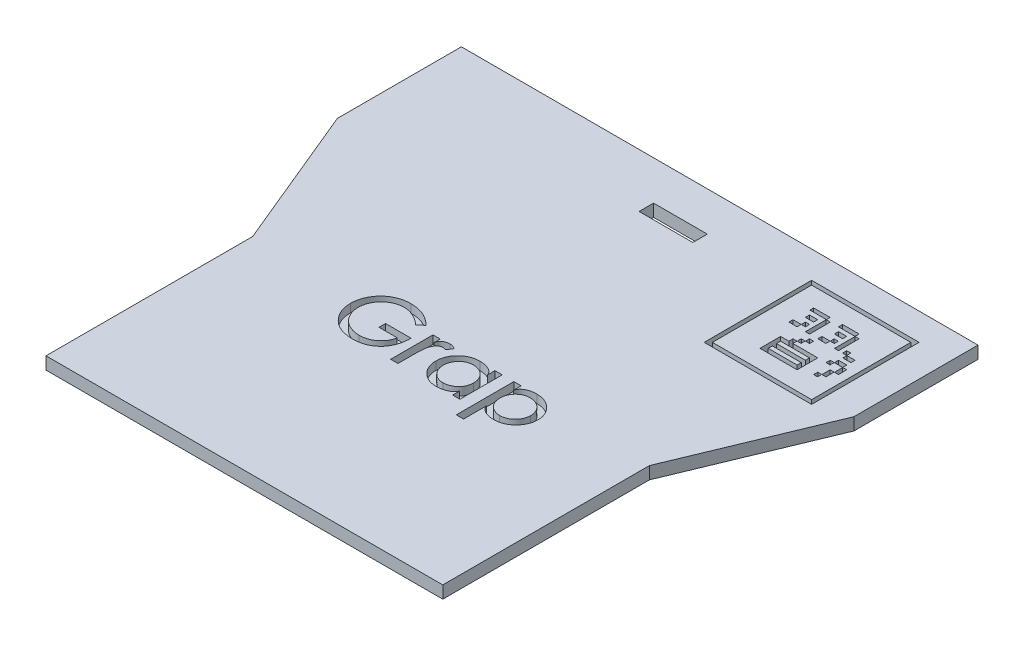
from build123d import *

# Parameters (mm, degrees)
CROQUIS1_W              = 40
CROQUIS1_H              = 20
CROQUIS1_W_2            = 20
CROQUIS1_H_2            = 40
SALIENTE_EXTRUIR1_DEPTH = 40
SALIENTE_EXTRUIR2_DEPTH = 5
CROQUIS3_W              = 13
CROQUIS3_H              = 3.5
CORTAR_EXTRUIR1_DEPTH   = 62
CROQUIS4_W              = 147.742850119
CROQUIS4_H              = 51.92034425
CORTAR_EXTRUIR2_DEPTH   = 152
CORTAR_EXTRUIR3_DEPTH   = 2
CROQUIS6_W              = 26
CROQUIS6_H              = 26
CROQUIS6_W_2            = 24
CROQUIS6_H_2            = 24
CORTAR_EXTRUIR7_DEPTH   = 2
CROQUIS7_W              = 3.990953792
CROQUIS7_H              = 0.897964604
CROQUIS7_W_2            = 1.970533435
CROQUIS7_H_2            = 0.997738449
CORTAR_EXTRUIR8_DEPTH   = 2
CROQUIS8_W              = 0.992886959
CROQUIS8_H              = 5.031193214
CORTAR_EXTRUIR10_DEPTH  = 2
CROQUIS9_W              = 1.005466888
CROQUIS9_H              = 1.003796718
CROQUIS9_W_2            = 1.973221998
CROQUIS9_H_2            = 1
CROQUIS9_W_3            = 4
CROQUIS9_W_4            = 0.964797176
CROQUIS9_H_3            = 5
CROQUIS9_W_5            = 2
CROQUIS9_W_6            = 1
CROQUIS9_H_4            = 0.952415725
CROQUIS9_W_7            = 1.95780875
CROQUIS9_W_8            = 1.970226015
CROQUIS9_W_9            = 0.956721573
CROQUIS9_W_10           = 0.966245303
CROQUIS9_H_5            = 2
CROQUIS9_W_11           = 0.963731959
CROQUIS9_W_12           = 0.946325397
CROQUIS9_W_13           = 0.94926307
CROQUIS9_W_14           = 0.978896183
CROQUIS9_H_6            = 1.388930129
CORTAR_EXTRUIR11_DEPTH  = 2
CROQUIS10_W             = 9
CROQUIS10_H             = 5
CROQUIS10_W_2           = 7
CROQUIS10_H_2           = 1
CORTAR_EXTRUIR12_DEPTH  = 2


with BuildPart() as part:
    # Croquis1 → Saliente-Extruir1 (new body)
    with BuildSketch(Plane(origin=(0, 0, 0), x_dir=(1, 0, 0), z_dir=(0, 1, 0))):
        Polygon((9.791730439, 53.63143583), (-115.208269561, 53.63143583), (-115.208269561, 23.63143583), (-100.708269561, -11.36856417), (-100.708269561, -61.36856417), (-4.708269561, -61.36856417), (-4.708269561, -11.36856417), (9.791730439, 23.63143583), align=None)
        with Locations((-90.208269561, 38.63143583)):
            Rectangle(CROQUIS1_W, CROQUIS1_H, mode=Mode.SUBTRACT)
        with Locations((-85.708269561, -36.36856417)):
            Rectangle(CROQUIS1_W_2, CROQUIS1_H_2, mode=Mode.SUBTRACT)
        with Locations((-15.208269561, 38.63143583)):
            Rectangle(CROQUIS1_W, CROQUIS1_H, mode=Mode.SUBTRACT)
        with Locations((-19.708269561, -36.36856417)):
            Rectangle(CROQUIS1_W_2, CROQUIS1_H_2, mode=Mode.SUBTRACT)
    extrude(amount=SALIENTE_EXTRUIR1_DEPTH)

    # Croquis2 → Saliente-Extruir2 (add)
    with BuildSketch(Plane.XZ):
        Polygon((9.791730439, -53.63143583), (9.791730439, -23.63143583), (-4.708269561, 11.36856417), (-4.708269561, 61.36856417), (-100.708269561, 61.36856417), (-100.708269561, 11.36856417), (-115.208269561, -23.63143583), (-115.208269561, -53.63143583), align=None)
    extrude(amount=SALIENTE_EXTRUIR2_DEPTH)

    # Croquis3 → Cortar-Extruir1 (cut)
    with BuildSketch(Plane(origin=(0, 40, 0), x_dir=(1, 0, 0), z_dir=(0, 1, 0))):
        with Locations((-52.708269561, 42.38143583)):
            Rectangle(CROQUIS3_W, CROQUIS3_H)
    extrude(amount=-CORTAR_EXTRUIR1_DEPTH, mode=Mode.SUBTRACT)

    # Croquis4 → Cortar-Extruir2 (cut)
    with BuildSketch(Plane(origin=(9.791730439, 0, 0), x_dir=(0, 0, -1), z_dir=(1, 0, 0))):
        with Locations((-9.648235569, 23.960172125)):
            Rectangle(CROQUIS4_W, CROQUIS4_H)
    extrude(amount=-CORTAR_EXTRUIR2_DEPTH, mode=Mode.SUBTRACT)

    # Croquis5 → Cortar-Extruir3 (cut)
    with BuildSketch(Plane(origin=(0, -2, 0), x_dir=(1, 0, 0), z_dir=(0, 1, 0))):
        with BuildLine():
            Line((-61.107219812, -9.007277638), (-62.44391686, -10.170341874))
            add(Edge.make_bspline(
                [(-62.44391686, -10.170341874), (-62.65362633, -9.987223191), (-63.061875839, -9.630738991), (-63.701108315, -9.159841224), (-64.343917636, -8.76265185), (-64.990474004, -8.44391251), (-65.62986377, -8.18862318), (-66.265000491, -8.013112652), (-66.890834022, -7.89844897), (-67.306999029, -7.884278333), (-67.51234134, -7.877286319)],
                knots=[0, 0, 0, 0, 0.000834946, 0.001625421, 0.002378884, 0.0030987, 0.003785538, 0.004440865, 0.005072944, 0.005688593, 0.005688593, 0.005688593, 0.005688593], degree=3))
            add(Edge.make_bspline(
                [(-67.51234134, -7.877286319), (-67.630951678, -7.879144317), (-67.867801497, -7.882854503), (-68.22117472, -7.921006086), (-68.571102497, -7.977916251), (-68.917797859, -8.059364387), (-69.261994259, -8.159789097), (-69.601057018, -8.287853385), (-69.937072461, -8.437654718), (-70.267317248, -8.610047847), (-70.588301816, -8.801288153), (-70.893374791, -9.011758013), (-71.180634208, -9.241115678), (-71.45061838, -9.488712221), (-71.701741729, -9.75492556), (-71.937725766, -10.035925909), (-72.152458558, -10.338300474), (-72.350120096, -10.655537634), (-72.524430099, -10.985384364), (-72.681321574, -11.319903304), (-72.810479557, -11.661931393), (-72.915006494, -12.01032992), (-72.998259409, -12.364643224), (-73.058694647, -12.724480991), (-73.096093346, -13.090985292), (-73.099796126, -13.336985007), (-73.101664256, -13.461097083)],
                knots=[0, 0, 0, 0, 0.000355705, 0.000710297, 0.001065072, 0.001418731, 0.001778016, 0.002139945, 0.002505133, 0.002881113, 0.00325688, 0.003625371, 0.003992095, 0.004358808, 0.004723372, 0.005089307, 0.005458714, 0.005834997, 0.006209823, 0.006577292, 0.006942771, 0.007305486, 0.007667823, 0.008033925, 0.008399488, 0.008771721, 0.008771721, 0.008771721, 0.008771721], degree=3))
            add(Edge.make_bspline(
                [(-73.101664256, -13.461097083), (-73.098504682, -13.587941548), (-73.092196404, -13.84119403), (-73.057173854, -14.218173757), (-72.993055754, -14.588222734), (-72.90399165, -14.951758064), (-72.791467129, -15.30922645), (-72.65346294, -15.661548507), (-72.486277482, -16.005193628), (-72.300871918, -16.343319206), (-72.092232737, -16.66783323), (-71.861846798, -16.973714613), (-71.617492157, -17.264914398), (-71.351833962, -17.533325948), (-71.072879774, -17.787930132), (-70.770904322, -18.017533791), (-70.454392656, -18.233422593), (-70.12123654, -18.428995674), (-69.774384603, -18.601474989), (-69.419586759, -18.753657627), (-69.05568389, -18.880888407), (-68.684923399, -18.985758492), (-68.305360383, -19.065503326), (-67.919749011, -19.122728841), (-67.525966888, -19.160829715), (-67.260709556, -19.16437919), (-67.126490645, -19.166175208)],
                knots=[0, 0, 0, 0, 0.000380588, 0.000759867, 0.001134582, 0.001506243, 0.00188193, 0.002258102, 0.002640243, 0.003027597, 0.003414431, 0.003796423, 0.004175782, 0.004553877, 0.004928562, 0.00530783, 0.005690806, 0.006077463, 0.006465718, 0.006852217, 0.007234876, 0.007621405, 0.008007354, 0.008397521, 0.008790521, 0.009193059, 0.009193059, 0.009193059, 0.009193059], degree=3))
            add(Edge.make_bspline(
                [(-67.126490645, -19.166175208), (-66.959121917, -19.162408694), (-66.628980803, -19.154979103), (-66.14438368, -19.098088106), (-65.678387423, -19.010247082), (-65.235740125, -18.873721965), (-64.809383598, -18.711337051), (-64.405678135, -18.504475756), (-64.019789839, -18.264628028), (-63.660010763, -17.986348269), (-63.32471731, -17.686623121), (-63.026126115, -17.36395103), (-62.759096656, -17.028800997), (-62.533961044, -16.673124203), (-62.338538456, -16.306889503), (-62.183737808, -15.922375459), (-62.063743442, -15.52284957), (-62.014118004, -15.247625132), (-61.989164256, -15.109230763)],
                knots=[0, 0, 0, 0, 0.000501977, 0.000990168, 0.001462037, 0.001922426, 0.002377938, 0.002829059, 0.003281005, 0.003739087, 0.004191822, 0.00462864, 0.005056499, 0.005475458, 0.005889687, 0.006300148, 0.006716981, 0.00713858, 0.00713858, 0.00713858, 0.00713858], degree=3))
            Line((-61.989164256, -15.109230763), (-66.398886479, -15.109230763))
            Line((-66.398886479, -15.109230763), (-66.398886479, -13.521730763))
            Line((-66.398886479, -13.521730763), (-60.225275367, -13.521730763))
            add(Edge.make_bspline(
                [(-60.225275367, -13.521730763), (-60.231527527, -13.793980078), (-60.243732443, -14.325441305), (-60.341714945, -15.100134558), (-60.486185382, -15.832718068), (-60.697254271, -16.520101513), (-60.964692169, -17.163253655), (-61.291326014, -17.762189768), (-61.676514098, -18.316735334), (-62.117658138, -18.82376331), (-62.60810364, -19.278560773), (-63.14264914, -19.676844687), (-63.723691118, -20.007408471), (-64.343808432, -20.282027775), (-65.006434363, -20.49421392), (-65.70986279, -20.644503632), (-66.455192559, -20.737476847), (-66.966359313, -20.748184662), (-67.228465472, -20.753675208)],
                knots=[0, 0, 0, 0, 0.000816469, 0.001593839, 0.002339208, 0.00305409, 0.003747138, 0.004425491, 0.005096758, 0.005768789, 0.006437721, 0.007099742, 0.007763956, 0.008438925, 0.009130969, 0.009847236, 0.010594179, 0.011380245, 0.011380245, 0.011380245, 0.011380245], degree=3))
            add(Edge.make_bspline(
                [(-67.228465472, -20.753675208), (-67.382858489, -20.751418732), (-67.688264344, -20.746955183), (-68.139766754, -20.715679742), (-68.579701615, -20.667349812), (-69.006250268, -20.594798045), (-69.421716477, -20.505037817), (-69.822717001, -20.390242146), (-70.214708335, -20.263038712), (-70.590754996, -20.105790221), (-70.95886701, -19.937053039), (-71.312939697, -19.7428591), (-71.653297914, -19.526558164), (-71.987145951, -19.296710566), (-72.301653498, -19.038793849), (-72.607369167, -18.765132721), (-72.899582508, -18.470176327), (-73.083437607, -18.260398035), (-73.176078319, -18.154695173)],
                knots=[0, 0, 0, 0, 0.000463152, 0.000916164, 0.001357179, 0.00179034, 0.002213637, 0.00263159, 0.003041217, 0.003449126, 0.003853556, 0.004255641, 0.004659385, 0.005063092, 0.005470711, 0.005878583, 0.00629369, 0.006715289, 0.006715289, 0.006715289, 0.006715289], degree=3))
            add(Edge.make_bspline(
                [(-73.176078319, -18.154695173), (-73.311849304, -17.987275031), (-73.580474619, -17.656031295), (-73.918956317, -17.119479296), (-74.216117932, -16.57026445), (-74.452356585, -15.996849783), (-74.637955631, -15.404828981), (-74.771064498, -14.792576435), (-74.848500143, -14.160380427), (-74.859832269, -13.732319551), (-74.865553145, -13.51621861)],
                knots=[0, 0, 0, 0, 0.000646128, 0.001278376, 0.00189979, 0.002517575, 0.003135607, 0.003758901, 0.004394742, 0.005043007, 0.005043007, 0.005043007, 0.005043007], degree=3))
            add(Edge.make_bspline(
                [(-74.865553145, -13.51621861), (-74.863492359, -13.354394254), (-74.859408626, -13.033716884), (-74.808754024, -12.557203514), (-74.736116743, -12.088345139), (-74.631169309, -11.627882325), (-74.495595779, -11.176753904), (-74.328942188, -10.734312058), (-74.134396836, -10.299011554), (-73.907076675, -9.876160561), (-73.659671625, -9.465850833), (-73.381624659, -9.080829051), (-73.087186955, -8.713847421), (-72.766050677, -8.373716003), (-72.427430399, -8.050970834), (-72.061510537, -7.756960842), (-71.675875094, -7.482950954), (-71.267211216, -7.235515897), (-70.842186206, -7.013162637), (-70.401701352, -6.818149926), (-69.946617037, -6.657667337), (-69.480103528, -6.519913615), (-68.998544662, -6.419729192), (-68.504453483, -6.345751385), (-67.996586453, -6.296002586), (-67.653019625, -6.291874171), (-67.479268423, -6.289786319)],
                knots=[0, 0, 0, 0, 0.000485265, 0.00096162, 0.001436026, 0.001908056, 0.002377156, 0.002848114, 0.00332552, 0.003806375, 0.004287561, 0.004761734, 0.005230048, 0.00569803, 0.006164002, 0.006632316, 0.007104893, 0.007582291, 0.008064297, 0.008543102, 0.009026052, 0.009511012, 0.010001292, 0.01050021, 0.011009488, 0.011530569, 0.011530569, 0.011530569, 0.011530569], degree=3))
            add(Edge.make_bspline(
                [(-67.479268423, -6.289786319), (-67.333161803, -6.292378423), (-67.042539755, -6.297534402), (-66.610098797, -6.324366182), (-66.184052819, -6.373747457), (-65.765341055, -6.447375953), (-65.351462363, -6.53324746), (-64.946234745, -6.64471331), (-64.54808097, -6.774623888), (-64.155045689, -6.923854221), (-63.76550445, -7.094966512), (-63.378364356, -7.290661939), (-62.995278363, -7.515819131), (-62.612206645, -7.763348679), (-62.231547946, -8.036706613), (-61.85390814, -8.336059014), (-61.47470908, -8.657252981), (-61.231028523, -8.889352829), (-61.107219812, -9.007277638)],
                knots=[0, 0, 0, 0, 0.000438355, 0.000871936, 0.001299261, 0.001724269, 0.002146983, 0.002566858, 0.002984337, 0.003403043, 0.003827559, 0.004260193, 0.004703588, 0.005159974, 0.005628061, 0.00610886, 0.006605398, 0.007118243, 0.007118243, 0.007118243, 0.007118243], degree=3))
        make_face()
        with BuildLine():
            Line((-58.28499759, -10.170341874), (-56.521108701, -10.170341874))
            Line((-56.521108701, -10.170341874), (-56.521108701, -11.622794131))
            add(Edge.make_bspline(
                [(-56.521108701, -11.622794131), (-56.510465377, -11.556388161), (-56.48969112, -11.426773126), (-56.437289176, -11.240510201), (-56.364810536, -11.067579679), (-56.273709525, -10.907784797), (-56.165669761, -10.760518615), (-56.039594821, -10.626701113), (-55.896071177, -10.504457911), (-55.678932125, -10.36473568), (-55.393842755, -10.216953615), (-55.036132033, -10.088701138), (-54.669931273, -10.007452807), (-54.421391637, -9.99845695), (-54.296955055, -9.993952985)],
                knots=[0, 0, 0, 0, 0.000201646, 0.000393585, 0.000578878, 0.000762793, 0.000944151, 0.001125487, 0.001313224, 0.001508147, 0.001898898, 0.002273765, 0.002645662, 0.003018558, 0.003018558, 0.003018558, 0.003018558], degree=3))
            add(Edge.make_bspline(
                [(-54.296955055, -9.993952985), (-54.184407983, -10.000636438), (-53.94796047, -10.014677546), (-53.584766275, -10.108294511), (-53.202324773, -10.262804002), (-52.94971593, -10.400916748), (-52.816942034, -10.473510277)],
                knots=[0, 0, 0, 0, 0.000337605, 0.000709267, 0.0011187, 0.00157234, 0.00157234, 0.00157234, 0.00157234], degree=3))
            Line((-52.816942034, -10.473510277), (-53.65203318, -11.755085798))
            add(Edge.make_bspline(
                [(-53.65203318, -11.755085798), (-53.747289377, -11.728139669), (-53.921304692, -11.678914116), (-54.161168606, -11.62876584), (-54.350949411, -11.590758995), (-54.462209024, -11.584215196), (-54.509172937, -11.581452985)],
                knots=[0, 0, 0, 0, 0.000296839, 0.000542269, 0.000735292, 0.000876284, 0.000876284, 0.000876284, 0.000876284], degree=3))
            add(Edge.make_bspline(
                [(-54.509172937, -11.581452985), (-54.586126859, -11.587096161), (-54.748096212, -11.598973678), (-54.989709004, -11.692327134), (-55.237778851, -11.836356844), (-55.44215635, -11.997628632), (-55.606116572, -12.15526273), (-55.723421432, -12.299858494), (-55.837270442, -12.463504589), (-55.944148836, -12.647858192), (-56.042783551, -12.853074289), (-56.136064933, -13.076785957), (-56.225669798, -13.319838392), (-56.275073858, -13.491062053), (-56.30062259, -13.579608367)],
                knots=[0, 0, 0, 0, 0.000230409, 0.000484954, 0.000767664, 0.001089642, 0.001263099, 0.001449068, 0.001647084, 0.001860747, 0.00208755, 0.002329662, 0.002587734, 0.002864126, 0.002864126, 0.002864126, 0.002864126], degree=3))
            add(Edge.make_bspline(
                [(-56.30062259, -13.579608367), (-56.319277658, -13.652858961), (-56.361133097, -13.817207636), (-56.400538299, -14.096205848), (-56.440212727, -14.429587293), (-56.468121616, -14.818685475), (-56.49384423, -15.262389382), (-56.508475488, -15.762350245), (-56.520608385, -16.318169452), (-56.520936776, -16.707746252), (-56.521108701, -16.911704722)],
                knots=[0, 0, 0, 0, 0.000226619, 0.000508454, 0.000844164, 0.001233952, 0.001678373, 0.002177497, 0.002734333, 0.003346188, 0.003346188, 0.003346188, 0.003346188], degree=3))
            Line((-56.521108701, -16.911704722), (-56.521108701, -20.40089743))
            Line((-56.521108701, -20.40089743), (-58.28499759, -20.40089743))
            Line((-58.28499759, -20.40089743), (-58.28499759, -10.170341874))
        make_face()
        with BuildLine():
            Line((-41.528053145, -10.170341874), (-41.528053145, -20.40089743))
            Line((-41.528053145, -20.40089743), (-43.291942034, -20.40089743))
            Line((-43.291942034, -20.40089743), (-43.291942034, -18.694886145))
            add(Edge.make_bspline(
                [(-43.291942034, -18.694886145), (-43.323297454, -18.76831767), (-43.386242471, -18.91572914), (-43.512123658, -19.121863732), (-43.659423894, -19.317070999), (-43.830777414, -19.498650983), (-44.02486067, -19.667199335), (-44.241329622, -19.822804651), (-44.482544059, -19.962164614), (-44.832258426, -20.134727292), (-45.299899647, -20.313733116), (-45.891223776, -20.463284101), (-46.508681524, -20.561645992), (-46.930497517, -20.572015006), (-47.144936826, -20.577286319)],
                knots=[0, 0, 0, 0, 0.000239271, 0.000480329, 0.000722315, 0.000971889, 0.001227789, 0.001492429, 0.00177037, 0.002062488, 0.002661851, 0.00326815, 0.003889857, 0.004532738, 0.004532738, 0.004532738, 0.004532738], degree=3))
            add(Edge.make_bspline(
                [(-47.144936826, -20.577286319), (-47.325231177, -20.572406265), (-47.680833422, -20.562781126), (-48.204498615, -20.489825414), (-48.707464217, -20.368415463), (-49.190935284, -20.199704618), (-49.653556363, -19.980435864), (-50.095530256, -19.712049787), (-50.516122511, -19.39499362), (-50.913028362, -19.037304594), (-51.27409929, -18.642740615), (-51.593714786, -18.22327916), (-51.861236703, -17.779707544), (-52.084376573, -17.317326872), (-52.255813074, -16.832036711), (-52.376541205, -16.325816628), (-52.449830498, -15.798557066), (-52.459334074, -15.440195676), (-52.464164256, -15.258058888)],
                knots=[0, 0, 0, 0, 0.00054076, 0.001066564, 0.001582621, 0.002090794, 0.00259996, 0.003115641, 0.003639295, 0.004177867, 0.004716255, 0.005241568, 0.005757249, 0.006267599, 0.006779288, 0.007298023, 0.007826558, 0.008372825, 0.008372825, 0.008372825, 0.008372825], degree=3))
            add(Edge.make_bspline(
                [(-52.464164256, -15.258058888), (-52.459579832, -15.080467732), (-52.450512314, -14.729210782), (-52.372983353, -14.213459372), (-52.25373258, -13.71550345), (-52.077240074, -13.240055053), (-51.856433167, -12.782195032), (-51.58420468, -12.344788973), (-51.262297132, -11.927272129), (-50.896362988, -11.533757119), (-50.494262812, -11.176965507), (-50.07074994, -10.859039848), (-49.62591905, -10.590788019), (-49.160572316, -10.371513687), (-48.67435413, -10.202795218), (-48.169516957, -10.08172788), (-47.644103373, -10.008276128), (-47.287570497, -9.99877979), (-47.106351756, -9.993952985)],
                knots=[0, 0, 0, 0, 0.000532501, 0.001053231, 0.001561255, 0.002066099, 0.002571484, 0.003083906, 0.003608698, 0.004150826, 0.004693501, 0.005219363, 0.005737402, 0.006249061, 0.006759836, 0.007278571, 0.007804376, 0.008347889, 0.008347889, 0.008347889, 0.008347889], degree=3))
            add(Edge.make_bspline(
                [(-47.106351756, -9.993952985), (-46.887286608, -9.999921151), (-46.457846241, -10.011620736), (-45.83054715, -10.115013972), (-45.232949811, -10.275775304), (-44.764228115, -10.46873416), (-44.415173654, -10.652706379), (-44.178848932, -10.803425059), (-43.96571511, -10.966654129), (-43.781694997, -11.146697175), (-43.619440189, -11.337653833), (-43.483936327, -11.543192362), (-43.371500708, -11.761936639), (-43.318559523, -11.916935125), (-43.291942034, -11.994864444)],
                knots=[0, 0, 0, 0, 0.000656779, 0.001287506, 0.001901968, 0.002510007, 0.002803448, 0.003084797, 0.003349968, 0.003607245, 0.003855674, 0.004100283, 0.004344332, 0.004591105, 0.004591105, 0.004591105, 0.004591105], degree=3))
            Line((-43.291942034, -11.994864444), (-43.291942034, -10.170341874))
            Line((-43.291942034, -10.170341874), (-41.528053145, -10.170341874))
        make_face()
        with BuildLine():
            add(Edge.make_bspline(
                [(-47.078790992, -11.581452985), (-47.234451772, -11.586418067), (-47.542671132, -11.59624928), (-47.995900014, -11.685088094), (-48.433023731, -11.829574425), (-48.850374385, -12.031097301), (-49.244707008, -12.283352816), (-49.599504077, -12.596912995), (-49.918549323, -12.960553796), (-50.194441625, -13.371765338), (-50.419695399, -13.816481787), (-50.581441073, -14.286484418), (-50.680830584, -14.773403673), (-50.693770452, -15.105096281), (-50.700275367, -15.27183927)],
                knots=[0, 0, 0, 0, 0.000466592, 0.000923884, 0.001379705, 0.001844437, 0.00231076, 0.00277952, 0.003259947, 0.00375834, 0.004261224, 0.004751062, 0.00524563, 0.005745575, 0.005745575, 0.005745575, 0.005745575], degree=3))
            add(Edge.make_bspline(
                [(-50.700275367, -15.27183927), (-50.693837406, -15.4385946), (-50.681065529, -15.769410229), (-50.580679427, -16.257287639), (-50.417515532, -16.729366217), (-50.188193524, -17.177978479), (-49.910898917, -17.592777032), (-49.591470562, -17.96174353), (-49.232947782, -18.275204431), (-48.841283567, -18.535891824), (-48.421894972, -18.734389088), (-47.990035302, -18.883719717), (-47.543475958, -18.971199474), (-47.241767808, -18.983560701), (-47.089815298, -18.989786319)],
                knots=[0, 0, 0, 0, 0.000499945, 0.00099181, 0.001487758, 0.001994344, 0.002498849, 0.002981352, 0.003454001, 0.003923344, 0.004388076, 0.00484216, 0.005291332, 0.005747094, 0.005747094, 0.005747094, 0.005747094], degree=3))
            add(Edge.make_bspline(
                [(-47.089815298, -18.989786319), (-46.92220477, -18.984059816), (-46.589985179, -18.972709358), (-46.098709235, -18.878232279), (-45.623795507, -18.722506376), (-45.166612346, -18.511396236), (-44.743507767, -18.246546677), (-44.363187276, -17.937210722), (-44.041556709, -17.578975587), (-43.76910722, -17.184650867), (-43.558202653, -16.752601406), (-43.401603662, -16.294885261), (-43.308579171, -15.809349864), (-43.297561182, -15.477109858), (-43.291942034, -15.307668263)],
                knots=[0, 0, 0, 0, 0.000502521, 0.000996044, 0.001494581, 0.001998913, 0.002502861, 0.002988431, 0.003464523, 0.003942311, 0.004421781, 0.004902011, 0.005390117, 0.00589814, 0.00589814, 0.00589814, 0.00589814], degree=3))
            add(Edge.make_bspline(
                [(-43.291942034, -15.307668263), (-43.29480958, -15.177951448), (-43.300467323, -14.922016829), (-43.354421639, -14.547261694), (-43.440469784, -14.188470106), (-43.55738282, -13.845386141), (-43.715111926, -13.520944159), (-43.901135174, -13.21032784), (-44.12826565, -12.92027627), (-44.382000521, -12.646492842), (-44.661452557, -12.397125084), (-44.959026197, -12.178261939), (-45.274638485, -11.994925588), (-45.604377876, -11.842319118), (-45.95181808, -11.727921517), (-46.312614464, -11.640126527), (-46.69065648, -11.5909645), (-46.948203272, -11.584653131), (-47.078790992, -11.581452985)],
                knots=[0, 0, 0, 0, 0.000388958, 0.000767425, 0.001133081, 0.001494799, 0.001852293, 0.002213413, 0.002578902, 0.002955276, 0.003332012, 0.003700802, 0.004061469, 0.004425281, 0.004788718, 0.005157054, 0.005537881, 0.005929594, 0.005929594, 0.005929594, 0.005929594], degree=3))
        make_face(mode=Mode.SUBTRACT)
        with BuildLine():
            Line((-38.705830923, -10.170341874), (-36.941942034, -10.170341874))
            Line((-36.941942034, -10.170341874), (-36.941942034, -11.994864444))
            add(Edge.make_bspline(
                [(-36.941942034, -11.994864444), (-36.91548374, -11.913219338), (-36.863152642, -11.751735837), (-36.749707228, -11.524860158), (-36.618149059, -11.311568904), (-36.4624396, -11.114993017), (-36.284966217, -10.933708064), (-36.08149601, -10.771994533), (-35.857767994, -10.621206924), (-35.524670337, -10.447766035), (-35.080239625, -10.262724972), (-34.51457304, -10.10666847), (-33.920945372, -10.009919733), (-33.515595135, -9.999335926), (-33.309433354, -9.993952985)],
                knots=[0, 0, 0, 0, 0.000257144, 0.000508597, 0.000758672, 0.001007895, 0.001259303, 0.001517993, 0.001786296, 0.002067416, 0.002643225, 0.003227, 0.003824197, 0.004442302, 0.004442302, 0.004442302, 0.004442302], degree=3))
            add(Edge.make_bspline(
                [(-33.309433354, -9.993952985), (-33.11900447, -9.998540734), (-32.743092526, -10.007597077), (-32.192416584, -10.084514062), (-31.662704185, -10.204523803), (-31.158155748, -10.379404874), (-30.674479487, -10.601779081), (-30.21308217, -10.8710737), (-29.777916896, -11.195681515), (-29.368618933, -11.560353214), (-28.997506074, -11.960954376), (-28.666551243, -12.379025274), (-28.390008181, -12.817549356), (-28.160456126, -13.271480672), (-27.988742923, -13.745284772), (-27.859131341, -14.23352272), (-27.783873847, -14.740323586), (-27.774473272, -15.084183814), (-27.769719812, -15.258058888)],
                knots=[0, 0, 0, 0, 0.000571047, 0.001127262, 0.001664775, 0.002198188, 0.002726004, 0.003259666, 0.003797666, 0.004352014, 0.004901932, 0.005433969, 0.005949319, 0.006454666, 0.006956923, 0.007458286, 0.007968108, 0.008489597, 0.008489597, 0.008489597, 0.008489597], degree=3))
            add(Edge.make_bspline(
                [(-27.769719812, -15.258058888), (-27.774373115, -15.435631924), (-27.783576867, -15.786853033), (-27.860273127, -16.303969903), (-27.983826622, -16.802848349), (-28.1592314, -17.282891461), (-28.383134747, -17.744883139), (-28.657905583, -18.18780421), (-28.982397649, -18.611039797), (-29.352283744, -19.009593621), (-29.755779687, -19.376568863), (-30.187964278, -19.699068813), (-30.644519078, -19.970266337), (-31.125126469, -20.191638027), (-31.627617085, -20.367227894), (-32.155740008, -20.486341665), (-32.705390641, -20.563844034), (-33.080410108, -20.572759146), (-33.270848284, -20.577286319)],
                knots=[0, 0, 0, 0, 0.000532501, 0.001053231, 0.001564593, 0.002072026, 0.002583573, 0.003102133, 0.003632977, 0.00418102, 0.00473127, 0.005267056, 0.005795971, 0.006321284, 0.006852092, 0.007389604, 0.007943089, 0.008514135, 0.008514135, 0.008514135, 0.008514135], degree=3))
            add(Edge.make_bspline(
                [(-33.270848284, -20.577286319), (-33.474209164, -20.57060564), (-33.874851525, -20.557443999), (-34.463778904, -20.462843878), (-35.024927683, -20.300793798), (-35.471298888, -20.120234201), (-35.80146653, -19.940132018), (-36.030509728, -19.793775457), (-36.237227881, -19.631267272), (-36.42209507, -19.454408249), (-36.586545508, -19.266070461), (-36.728641636, -19.063234239), (-36.846900989, -18.845077555), (-36.910200104, -18.69181491), (-36.941942034, -18.61495993)],
                knots=[0, 0, 0, 0, 0.00060999, 0.001201745, 0.001783616, 0.002359425, 0.002641853, 0.002910948, 0.003173947, 0.003429312, 0.003677436, 0.003922866, 0.00417076, 0.004420105, 0.004420105, 0.004420105, 0.004420105], degree=3))
            Line((-36.941942034, -18.61495993), (-36.941942034, -24.105064097))
            Line((-36.941942034, -24.105064097), (-38.705830923, -24.105064097))
            Line((-38.705830923, -24.105064097), (-38.705830923, -10.170341874))
        make_face()
        with BuildLine():
            add(Edge.make_bspline(
                [(-33.331481965, -11.581452985), (-33.452944198, -11.584433759), (-33.692314001, -11.590308072), (-34.044475421, -11.64284041), (-34.383952248, -11.720638242), (-34.710910743, -11.835738035), (-35.023726743, -11.984093293), (-35.323377952, -12.16589515), (-35.612366927, -12.375413091), (-35.882200652, -12.619116293), (-36.128524837, -12.888311155), (-36.350017186, -13.175139673), (-36.530995646, -13.485807543), (-36.680608411, -13.813803216), (-36.800859513, -14.159249768), (-36.881903862, -14.525572127), (-36.933037074, -14.910259734), (-36.938932783, -15.173372085), (-36.941942034, -15.307668263)],
                knots=[0, 0, 0, 0, 0.000364178, 0.000717698, 0.00106599, 0.001407677, 0.001755336, 0.002102743, 0.002457753, 0.002824653, 0.003191367, 0.003551317, 0.003909607, 0.004267261, 0.004631584, 0.005004664, 0.005390957, 0.005793684, 0.005793684, 0.005793684, 0.005793684], degree=3))
            add(Edge.make_bspline(
                [(-36.941942034, -15.307668263), (-36.936393304, -15.484453092), (-36.925564599, -15.829460106), (-36.832834653, -16.331456702), (-36.677580941, -16.800112925), (-36.46483534, -17.235377492), (-36.197230687, -17.630479388), (-35.879194777, -17.980006745), (-35.518759782, -18.288364351), (-35.110777311, -18.537444185), (-34.678658513, -18.738353999), (-34.231331974, -18.881399797), (-33.775486888, -18.975670597), (-33.466991241, -18.985069826), (-33.31218943, -18.989786319)],
                knots=[0, 0, 0, 0, 0.000530034, 0.001034396, 0.001525079, 0.002007022, 0.002483257, 0.002951563, 0.003420906, 0.003901191, 0.004380883, 0.004847182, 0.005307702, 0.005771543, 0.005771543, 0.005771543, 0.005771543], degree=3))
            add(Edge.make_bspline(
                [(-33.31218943, -18.989786319), (-33.148260701, -18.984010525), (-32.823346941, -18.972562654), (-32.344475913, -18.879120768), (-31.883836759, -18.721568367), (-31.440338993, -18.511452251), (-31.027547133, -18.241841948), (-30.655004032, -17.918350458), (-30.3239674, -17.547310328), (-30.046655227, -17.12867257), (-29.817394722, -16.684092763), (-29.654486797, -16.221355161), (-29.553050113, -15.749361748), (-29.54009952, -15.43126762), (-29.533608701, -15.27183927)],
                knots=[0, 0, 0, 0, 0.000491517, 0.000974209, 0.001457049, 0.001948914, 0.002442737, 0.002931208, 0.003425131, 0.003929636, 0.004433764, 0.004921909, 0.005397569, 0.005875516, 0.005875516, 0.005875516, 0.005875516], degree=3))
            add(Edge.make_bspline(
                [(-29.533608701, -15.27183927), (-29.540030176, -15.111482825), (-29.552805858, -14.792449771), (-29.654226226, -14.321617034), (-29.814580313, -13.862403676), (-30.040864601, -13.422965171), (-30.316982508, -13.011110899), (-30.640238568, -12.639868824), (-31.015111573, -12.324151507), (-31.427797701, -12.056698915), (-31.873039384, -11.845547611), (-32.341336506, -11.692174184), (-32.829803311, -11.598380889), (-33.16294936, -11.587139701), (-33.331481965, -11.581452985)],
                knots=[0, 0, 0, 0, 0.000480696, 0.000956357, 0.001438387, 0.001936353, 0.002434746, 0.002922953, 0.003407834, 0.003900154, 0.004394507, 0.00488171, 0.005375232, 0.005880504, 0.005880504, 0.005880504, 0.005880504], degree=3))
        make_face(mode=Mode.SUBTRACT)
    extrude(amount=-CORTAR_EXTRUIR3_DEPTH, mode=Mode.SUBTRACT)

    # Croquis6 → Cortar-Extruir7 (cut)
    with BuildSketch(Plane(origin=(0, -2, 0), x_dir=(1, 0, 0), z_dir=(0, 1, 0))):
        with Locations((-10.907863583, 34.071331847)):
            Rectangle(CROQUIS6_W, CROQUIS6_H)
        with Locations((-10.907863583, 34.071331847)):
            Rectangle(CROQUIS6_W_2, CROQUIS6_H_2, mode=Mode.SUBTRACT)
    extrude(amount=-CORTAR_EXTRUIR7_DEPTH, mode=Mode.SUBTRACT)

    # Croquis7 → Cortar-Extruir8 (cut)
    with BuildSketch(Plane(origin=(0, -2, 0), x_dir=(1, 0, 0), z_dir=(0, 1, 0))):
        with Locations((-15.89081471, 41.079155602)):
            Rectangle(CROQUIS7_W, CROQUIS7_H)
        with Locations((-15.903286441, 39.058735244)):
            Rectangle(CROQUIS7_W_2, CROQUIS7_H_2)
    extrude(amount=-CORTAR_EXTRUIR8_DEPTH, mode=Mode.SUBTRACT)

    # Croquis8 → Cortar-Extruir10 (cut)
    with BuildSketch(Plane(origin=(0, -2, 0), x_dir=(1, 0, 0), z_dir=(0, 1, 0))):
        with Locations((-13.394042845, 38.057303822)):
            Rectangle(CROQUIS8_W, CROQUIS8_H)
    extrude(amount=-CORTAR_EXTRUIR10_DEPTH, mode=Mode.SUBTRACT)

    # Croquis9 → Cortar-Extruir11 (cut)
    with BuildSketch(Plane(origin=(0, -2, 0), x_dir=(1, 0, 0), z_dir=(0, 1, 0))):
        with Locations((-15.410597027, 37.073230206)):
            Rectangle(CROQUIS9_W, CROQUIS9_H)
        with Locations((-16.921252584, 36.071331847)):
            Rectangle(CROQUIS9_W_2, CROQUIS9_H_2)
        with Locations((-8.907863583, 41.071331847)):
            Rectangle(CROQUIS9_W_3, CROQUIS9_H_2)
        with Locations((-6.390262171, 38.071331847)):
            Rectangle(CROQUIS9_W_4, CROQUIS9_H_3)
        with Locations((-8.907863583, 39.071331847)):
            Rectangle(CROQUIS9_W_5, CROQUIS9_H_2)
        with Locations((-4.407863583, 36.071331847)):
            Rectangle(CROQUIS9_W_6, CROQUIS9_H_2)
        with Locations((-8.407863583, 37.04753971)):
            Rectangle(CROQUIS9_W_6, CROQUIS9_H_4)
        with Locations((-9.928959208, 36.071331847)):
            Rectangle(CROQUIS9_W_7, CROQUIS9_H_2)
        with Locations((-2.892976591, 35.071331847)):
            Rectangle(CROQUIS9_W_8, CROQUIS9_H_2)
        with Locations((-2.907863583, 33.071331847)):
            Rectangle(CROQUIS9_W_5, CROQUIS9_H_2)
        with Locations((-4.429502797, 32.071331847)):
            Rectangle(CROQUIS9_W_9, CROQUIS9_H_2)
        with Locations((-1.390986235, 31.571331847)):
            Rectangle(CROQUIS9_W_10, CROQUIS9_H_5)
        with Locations((-2.425997603, 29.571331847)):
            Rectangle(CROQUIS9_W_11, CROQUIS9_H_5)
        with Locations((-3.434700885, 28.071331847)):
            Rectangle(CROQUIS9_W_12, CROQUIS9_H_2)
        with Locations((-11.407863583, 34.071331847)):
            Rectangle(CROQUIS9_W_6, CROQUIS9_H_2)
        with Locations((-12.433232048, 33.071331847)):
            Rectangle(CROQUIS9_W_13, CROQUIS9_H_2)
        with Locations((-13.418415492, 31.876866783)):
            Rectangle(CROQUIS9_W_14, CROQUIS9_H_6)
    extrude(amount=-CORTAR_EXTRUIR11_DEPTH, mode=Mode.SUBTRACT)

    # Croquis10 → Cortar-Extruir12 (cut)
    with BuildSketch(Plane(origin=(0, -2, 0), x_dir=(1, 0, 0), z_dir=(0, 1, 0))):
        with Locations((-11.407863583, 29.071331847)):
            Rectangle(CROQUIS10_W, CROQUIS10_H)
        with Locations((-11.407863583, 30.071331847)):
            Rectangle(CROQUIS10_W_2, CROQUIS10_H_2, mode=Mode.SUBTRACT)
        with Locations((-11.407863583, 28.071331847)):
            Rectangle(CROQUIS10_W_2, CROQUIS10_H_2, mode=Mode.SUBTRACT)
    extrude(amount=-CORTAR_EXTRUIR12_DEPTH, mode=Mode.SUBTRACT)


solid = part.part
